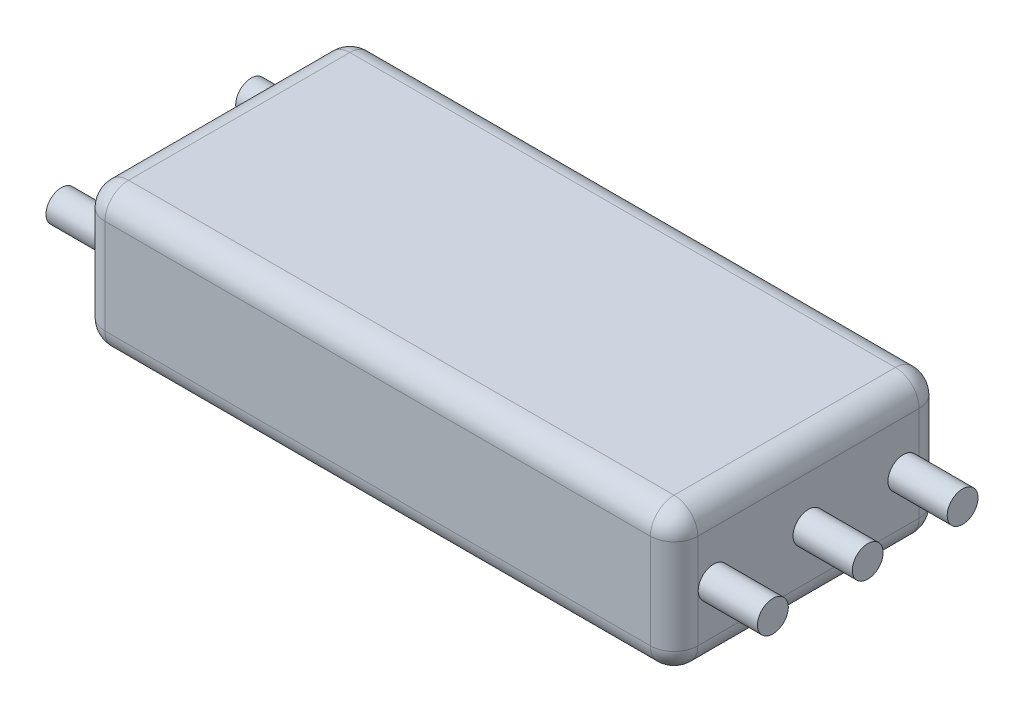
from build123d import *

# Parameters (mm, degrees)
SKETCH1_W           = 63.5
SKETCH1_H           = 28.7782
BOSS_EXTRUDE1_DEPTH = 7.62
FILLET1_R           = 2.54
BOSS_EXTRUDE2_START = 31.75
SKETCH2_R           = 1.651
BOSS_EXTRUDE2_DEPTH = 6.35
BOSS_EXTRUDE3_START = -31.75
SKETCH2_2_R         = 1.651
BOSS_EXTRUDE3_DEPTH = 6.35


with BuildPart() as part:
    # Sketch1 → Boss-Extrude1 (new body, symmetric)
    with BuildSketch(Plane(origin=(0, 0, 0), x_dir=(1, 0, 0), z_dir=(0, 1, 0))):
        Rectangle(SKETCH1_W, SKETCH1_H)
    extrude(amount=BOSS_EXTRUDE1_DEPTH, both=True)

    # Fillet1
    fillet1_edges = [part.edges().sort_by_distance(p)[0] for p in [
        (-31.75, 7.62, 0),
        (0, 7.62, 14.3891),
        (31.75, 7.62, 0),
        (0, -7.62, 14.3891),
        (-31.75, -7.62, 0),
        (0, -7.62, -14.3891),
        (31.75, -7.62, 0),
        (31.75, 0, 14.3891),
        (-31.75, 0, 14.3891),
        (-31.75, 0, -14.3891),
        (31.75, 0, -14.3891),
        (0, 7.62, -14.3891),
    ]]
    fillet(fillet1_edges, radius=FILLET1_R)

    # Sketch2 → Boss-Extrude2 (add)
    with BuildSketch(Plane(origin=(0, 0, 0), x_dir=(0, 0, -1), z_dir=(1, 0, 0)).offset(BOSS_EXTRUDE2_START)):
        Circle(SKETCH2_R)
        with Locations((10.16, 0)):
            Circle(SKETCH2_R)
        with Locations((-10.16, 0)):
            Circle(SKETCH2_R)
    extrude(amount=BOSS_EXTRUDE2_DEPTH)

    # Sketch2_2 → Boss-Extrude3 (add)
    with BuildSketch(Plane(origin=(0, 0, 0), x_dir=(0, 0, -1), z_dir=(1, 0, 0)).offset(BOSS_EXTRUDE3_START)):
        with Locations((10.16, 0)):
            Circle(SKETCH2_2_R)
        with Locations((-10.16, 0)):
            Circle(SKETCH2_2_R)
    extrude(amount=-BOSS_EXTRUDE3_DEPTH)


solid = part.part
